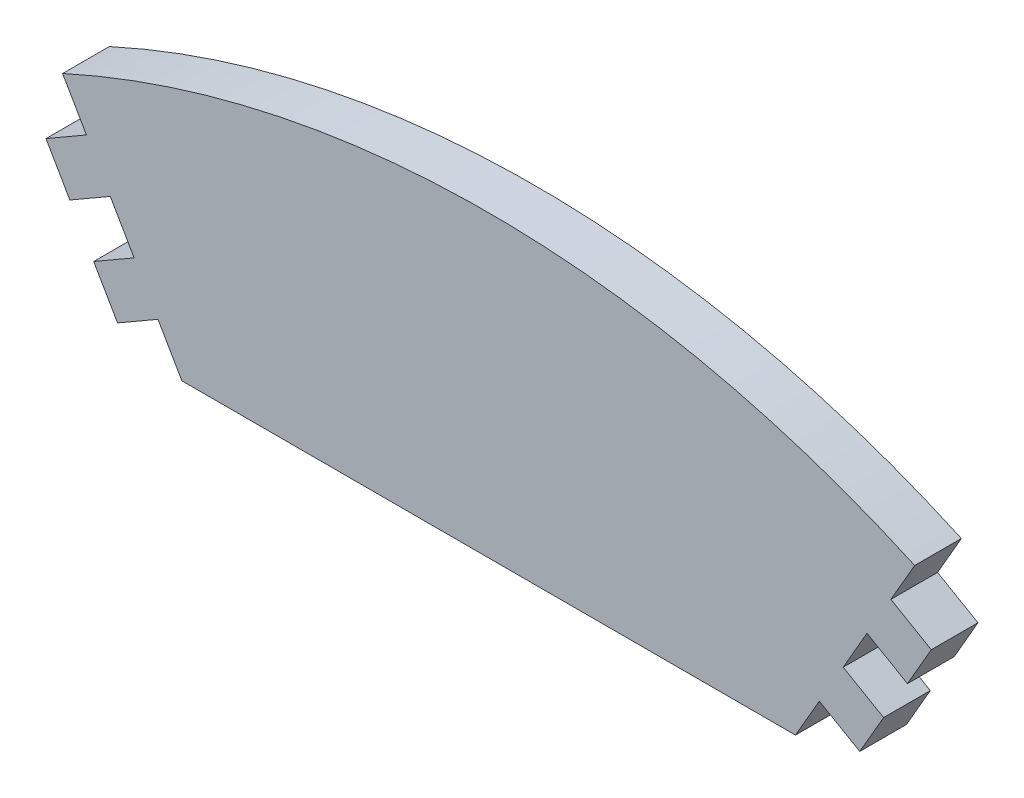
from build123d import *

# Parameters (mm, degrees)
BOSS_EXTRUDE1_DEPTH = 5


with BuildPart() as part:
    # Sketch1 → Boss-Extrude1 (new body)
    with BuildSketch(Plane.XY):
        with BuildLine():
            Line((-32.85, 77.986683936), (32.85, 77.986683936))
            Line((32.85, 77.986683936), (35.403, 82.408609648))
            Line((35.403, 82.408609648), (39.733127019, 79.908609648))
            Line((39.733127019, 79.908609648), (42.286127019, 84.330535359))
            Line((42.286127019, 84.330535359), (37.956, 86.830535359))
            Line((37.956, 86.830535359), (40.509, 91.252461071))
            Line((40.509, 91.252461071), (44.839127019, 88.752461071))
            Line((44.839127019, 88.752461071), (47.392127019, 93.174386783))
            Line((47.392127019, 93.174386783), (43.062, 95.674386783))
            Line((43.062, 95.674386783), (45.615, 100.096312495))
            ThreePointArc((45.615, 100.096312495), (0, 110), (-45.615, 100.096312495))
            Line((-45.615, 100.096312495), (-43.062, 95.674386783))
            Line((-43.062, 95.674386783), (-47.392127019, 93.174386783))
            Line((-47.392127019, 93.174386783), (-44.839127019, 88.752461071))
            Line((-44.839127019, 88.752461071), (-40.509, 91.252461071))
            Line((-40.509, 91.252461071), (-37.956, 86.830535359))
            Line((-37.956, 86.830535359), (-42.286127019, 84.330535359))
            Line((-42.286127019, 84.330535359), (-39.733127019, 79.908609648))
            Line((-39.733127019, 79.908609648), (-35.403, 82.408609648))
            Line((-35.403, 82.408609648), (-32.85, 77.986683936))
        make_face()
    extrude(amount=BOSS_EXTRUDE1_DEPTH)


solid = part.part
